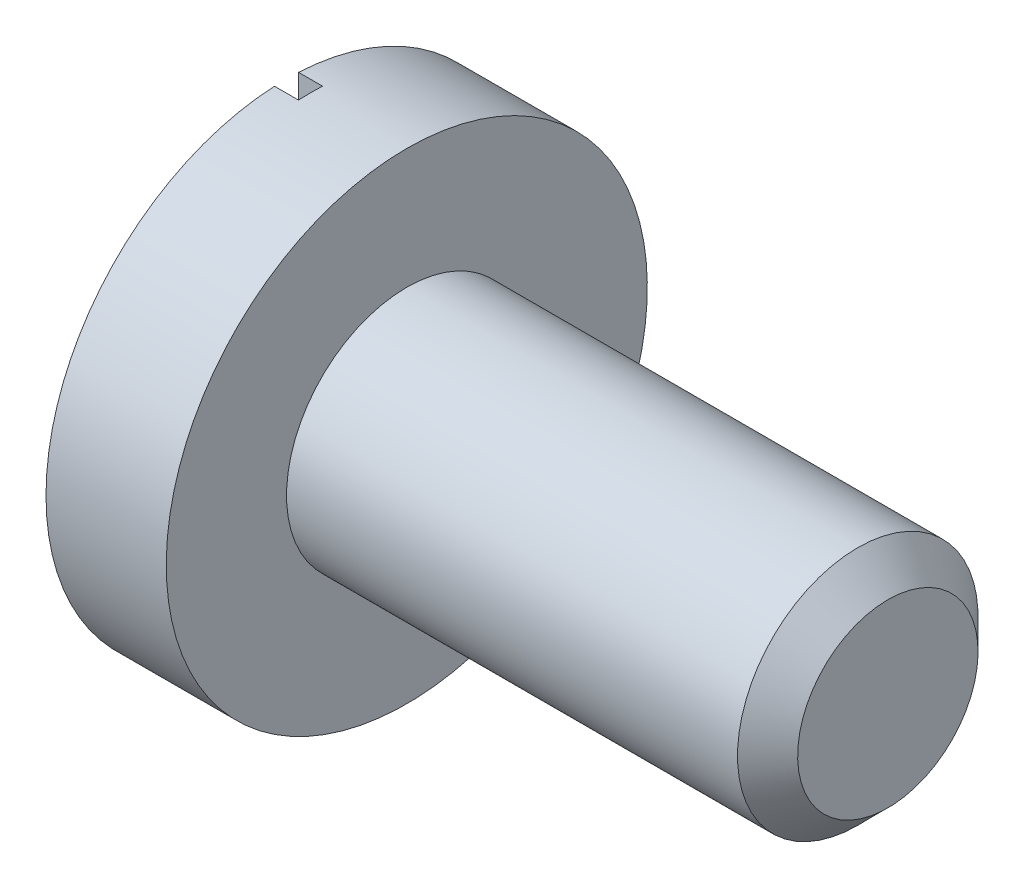
from build123d import *

# Parameters (mm, degrees)
CHAFL_N1_SIZE         = 0.125
CORTAR_EXTRUIR1_DEPTH = 0.1


with BuildPart() as part:
    # Croquis1 → Revolución1 (revolve)
    with BuildSketch(Plane.XY):
        Polygon((0, 0), (0, 1), (0.5, 1), (0.5, 0.5), (2.5, 0.5), (2.5, 0), align=None)
    revolve(axis=Axis((2.5, 0, 0), (-1, 0, 0)))

    # Chaflán1
    chafl_n1_edges = [part.edges().sort_by_distance(p)[0] for p in [
        (2.5, -0.5, 0),
    ]]
    chamfer(chafl_n1_edges, length=CHAFL_N1_SIZE)

    # Croquis5 → Cortar-Extruir1 (cut)
    with BuildSketch(Plane.ZY):
        with BuildLine():
            Line((-0.05, 0.998749218), (-0.05, -0.998749218))
            ThreePointArc((-0.05, -0.998749218), (0, -1), (0.05, -0.998749218))
            Line((0.05, -0.998749218), (0.05, 0.998749218))
            ThreePointArc((0.05, 0.998749218), (0, 1), (-0.05, 0.998749218))
        make_face()
    extrude(amount=-CORTAR_EXTRUIR1_DEPTH, mode=Mode.SUBTRACT)


solid = part.part
